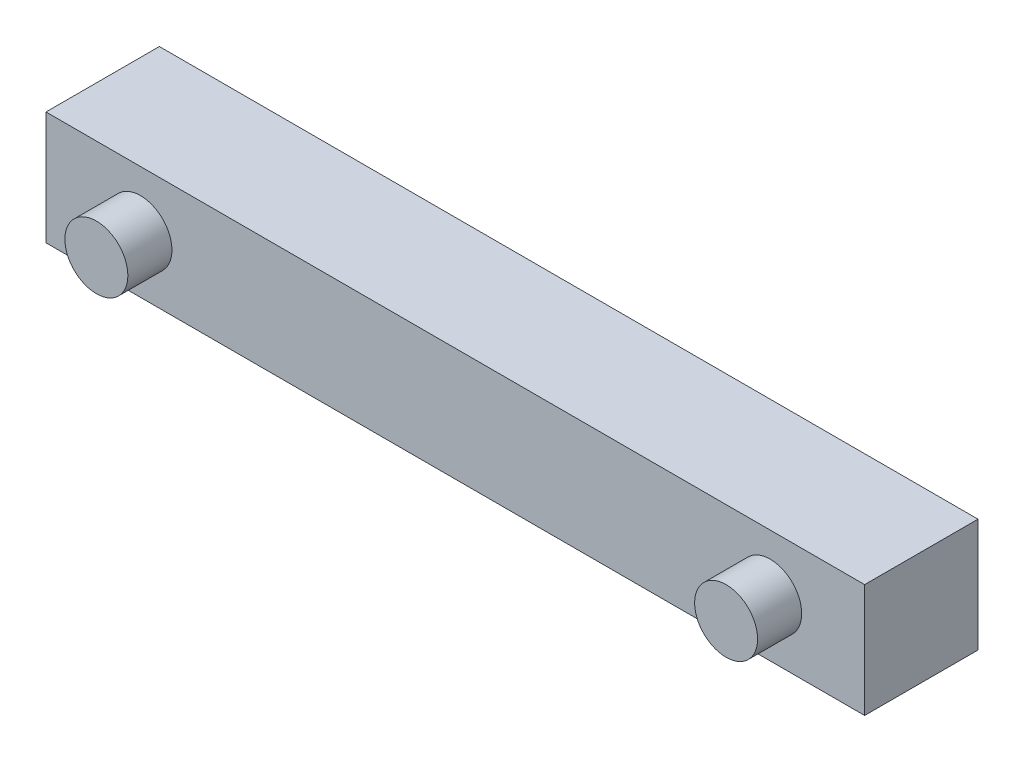
from build123d import *

# Parameters (mm, degrees)
SKETCH1_W           = 65
SKETCH1_H           = 9
BOSS_EXTRUDE1_DEPTH = 9
SKETCH2_R           = 2.5
BOSS_EXTRUDE2_DEPTH = 3.5


with BuildPart() as part:
    # Sketch1 → Boss-Extrude1 (new body)
    with BuildSketch(Plane.XY):
        with Locations((32.5, 4.5)):
            Rectangle(SKETCH1_W, SKETCH1_H)
    extrude(amount=BOSS_EXTRUDE1_DEPTH)

    # Sketch2 → Boss-Extrude2 (add)
    with BuildSketch(Plane.XY.offset(9)):
        with Locations(Location((7.5, 4.5, 0), (0, 0, 180))):  # turned: the seam where the file's is
            Circle(SKETCH2_R)
        with Locations(Location((57.5, 4.5, 0), (0, 0, 180))):  # turned: the seam where the file's is
            Circle(SKETCH2_R)
    extrude(amount=BOSS_EXTRUDE2_DEPTH)


solid = part.part
